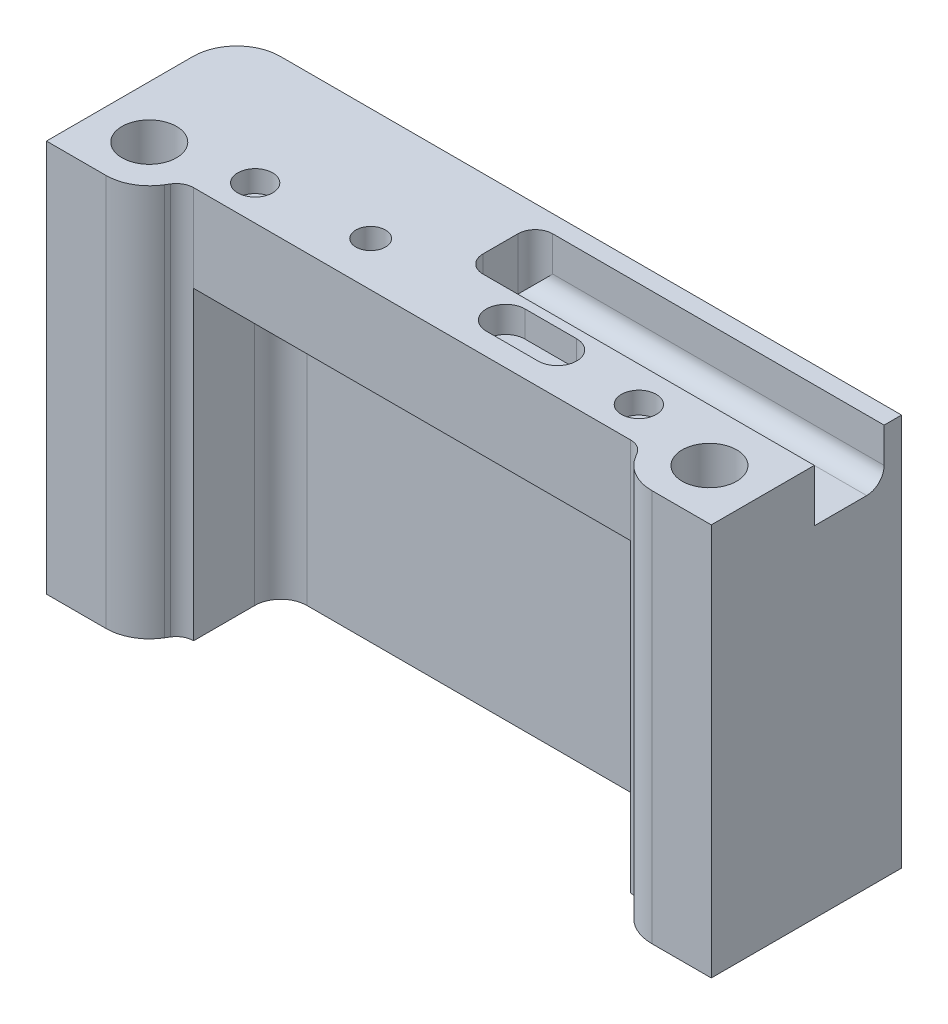
from build123d import *

# Parameters (mm, degrees)
SKETCH1_R                      = 2
SKETCH1_R_2                    = 3.125
SKETCH1_R_3                    = 1.7
BOSS_EXTRUDE1_DEPTH            = 10
FILLET2_R                      = 5
FILLET1_R                      = 2
SKETCH1_4_R                    = 3.125
CUT_EXTRUDE3_DEPTH             = 5.07
SKETCH1_7_R                    = 1.7
CUT_EXTRUDE6_DEPTH             = 10
CUT_EXTRUDE5_DEPTH             = 3
SKETCH1_5_R                    = 2
CUT_EXTRUDE4_DEPTH             = 2.48
SKETCH4_R                      = 1.5
CUT_EXTRUDE7_DEPTH             = 10
SKETCH5_R                      = 2.725
CUT_EXTRUDE8_DEPTH             = 2.8
BOSS_EXTRUDE2_DEPTH            = 10
BOSS_EXTRUDE3_DEPTH            = 35
FILLET13_R                     = 5
SKETCH10_W                     = 8
SKETCH10_H                     = 6
CUT_EXTRUDE12_DEPTH            = 40
FILLET14_R                     = 2
SKETCH27_W                     = 50.098907978
SKETCH27_H                     = 10
CUT_EXTRUDE22_DEPTH            = 35
FILLET17_R                     = 3
CBORE_FOR_M3_SHCS1_D           = 3.4
CBORE_FOR_M3_SHCS1_DEPTH       = 20
CBORE_FOR_M3_SHCS1_CBORE_D     = 6.5
CBORE_FOR_M3_SHCS1_CBORE_DEPTH = 3
CBORE_FOR_M3_SHCS1_TIP         = 1.021463052


with BuildPart() as part:
    # Sketch1 → Boss-Extrude1 (new body)
    with BuildSketch(Plane(origin=(0, 0, 0), x_dir=(1, 0, 0), z_dir=(0, 1, 0))):
        with BuildLine():
            ThreePointArc((-11.409245094, 8.977987014), (-9.849239736, 9.28), (-8.289234378, 8.977987014))
            ThreePointArc((-8.289234378, 8.977987014), (-5.835653376, 8.254222737), (-3.289234378, 8.01))
            Line((-3.289234378, 8.01), (38.12, 8.01))
            Line((38.12, 8.01), (38.12, -3.81))
            Line((38.12, -3.81), (28.478275237, -3.81))
            Line((28.478275237, -3.81), (26.178275237, 0))
            Line((26.178275237, 0), (-26.178275237, 0))
            Line((-26.178275237, 0), (-28.478275237, -3.81))
            Line((-28.478275237, -3.81), (-38.12, -3.81))
            Line((-38.12, -3.81), (-38.12, 8.01))
            Line((-38.12, 8.01), (-16.409245094, 8.01))
            ThreePointArc((-16.409245094, 8.01), (-13.862826096, 8.254222737), (-11.409245094, 8.977987014))
        make_face()
        with Locations((22, 4.005)):
            Circle(SKETCH1_R, mode=Mode.SUBTRACT)
        with Locations((-22, 4.005)):
            Circle(SKETCH1_R, mode=Mode.SUBTRACT)
        with Locations((-32.12, 1.98)):
            Circle(SKETCH1_R_2, mode=Mode.SUBTRACT)
        with Locations((32.12, 1.98)):
            Circle(SKETCH1_R_2, mode=Mode.SUBTRACT)
        with Locations((-9.849239736, 5.1)):
            Circle(SKETCH1_R_3, mode=Mode.SUBTRACT)
        with BuildLine():
            ThreePointArc((11.912105026, 2.53), (14.127105026, 4.745), (11.912105026, 6.96))
            Line((11.912105026, 6.96), (5.992105026, 6.96))
            ThreePointArc((5.992105026, 6.96), (3.777105026, 4.745), (5.992105026, 2.53))
            Line((5.992105026, 2.53), (11.912105026, 2.53))
        make_face(mode=Mode.SUBTRACT)
        with Locations((-22, 4.005)):
            Circle(SKETCH1_R)
        with Locations((-9.849239736, 5.1)):
            Circle(SKETCH1_R_3)
        with Locations((-32.12, 1.98)):
            Circle(SKETCH1_R_2)
        with BuildLine():
            Line((5.992105026, 2.53), (11.912105026, 2.53))
            ThreePointArc((11.912105026, 2.53), (14.127105026, 4.745), (11.912105026, 6.96))
            Line((11.912105026, 6.96), (5.992105026, 6.96))
            ThreePointArc((5.992105026, 6.96), (3.777105026, 4.745), (5.992105026, 2.53))
        make_face()
        with Locations((22, 4.005)):
            Circle(SKETCH1_R)
        with Locations((32.12, 1.98)):
            Circle(SKETCH1_R_2)
    extrude(amount=-BOSS_EXTRUDE1_DEPTH)

    # Fillet2
    fillet2_edges = [part.edges().sort_by_distance(p)[0] for p in [
        (28.478275237, -5, 3.81),
        (-28.478275237, -5, 3.81),
    ]]
    fillet(fillet2_edges, radius=FILLET2_R)

    # Fillet1
    fillet1_edges = [part.edges().sort_by_distance(p)[0] for p in [
        (26.178275237, -5, 0),
        (-26.178275237, -5, 0),
    ]]
    fillet(fillet1_edges, radius=FILLET1_R)

    # Sketch1_4 → Cut-Extrude3 (cut)
    with BuildSketch(Plane(origin=(0, 0, 0), x_dir=(1, 0, 0), z_dir=(0, 1, 0))):
        with Locations(Location((32.12, 1.98, 0), (0, 0, 270))):
            Circle(SKETCH1_4_R)
        with Locations(Location((-32.12, 1.98, 0), (0, 0, 270))):
            Circle(SKETCH1_4_R)
    extrude(amount=-CUT_EXTRUDE3_DEPTH, mode=Mode.SUBTRACT)

    # Sketch1_7 → Cut-Extrude6 (cut)
    with BuildSketch(Plane(origin=(0, 0, 0), x_dir=(1, 0, 0), z_dir=(0, 1, 0))):
        with Locations(Location((-9.849239736, 5.1, 0), (0, 0, 270))):
            Circle(SKETCH1_7_R)
    extrude(amount=-CUT_EXTRUDE6_DEPTH, mode=Mode.SUBTRACT)

    # Sketch1_6 → Cut-Extrude5 (cut)
    with BuildSketch(Plane(origin=(0, 0, 0), x_dir=(1, 0, 0), z_dir=(0, 1, 0))):
        with BuildLine():
            Line((5.992105026, 2.53), (11.912105026, 2.53))
            ThreePointArc((11.912105026, 2.53), (14.127105026, 4.745), (11.912105026, 6.96))
            Line((11.912105026, 6.96), (5.992105026, 6.96))
            ThreePointArc((5.992105026, 6.96), (3.777105026, 4.745), (5.992105026, 2.53))
        make_face()
    extrude(amount=-CUT_EXTRUDE5_DEPTH, mode=Mode.SUBTRACT)

    # Sketch1_5 → Cut-Extrude4 (cut)
    with BuildSketch(Plane(origin=(0, 0, 0), x_dir=(1, 0, 0), z_dir=(0, 1, 0))):
        with Locations(Location((-22, 4.005, 0), (0, 0, 270))):
            Circle(SKETCH1_5_R)
        with Locations(Location((22, 4.005, 0), (0, 0, 270))):
            Circle(SKETCH1_5_R)
    extrude(amount=-CUT_EXTRUDE4_DEPTH, mode=Mode.SUBTRACT)

    # Sketch4 → Cut-Extrude7 (cut)
    with BuildSketch(Plane(origin=(0, 0, 0), x_dir=(1, 0, 0), z_dir=(0, 1, 0))):
        with Locations(Location((-22, 4.005, 0), (0, 0, 270))):
            Circle(SKETCH4_R)
        with Locations(Location((22, 4.005, 0), (0, 0, 270))):
            Circle(SKETCH4_R)
    extrude(amount=-CUT_EXTRUDE7_DEPTH, mode=Mode.SUBTRACT)

    # Sketch5 → Cut-Extrude8 (cut)
    with BuildSketch(Plane.XZ.offset(10)):
        with Locations(Location((22, -4.005, 0), (0, 0, 270))):
            Circle(SKETCH5_R)
        with Locations(Location((-22, -4.005, 0), (0, 0, 90))):
            Circle(SKETCH5_R)
    extrude(amount=-CUT_EXTRUDE8_DEPTH, mode=Mode.SUBTRACT)

    # Sketch6 → Boss-Extrude2 (add)
    with BuildSketch(Plane(origin=(0, 0, 0), x_dir=(1, 0, 0), z_dir=(0, 1, 0))):
        with BuildLine():
            Line((-38.12, 8.01), (-38.12, 18.01))
            Line((-38.12, 18.01), (38.12, 18.01))
            Line((38.12, 18.01), (38.12, 8.01))
            Line((38.12, 8.01), (-3.289234378, 8.01))
            ThreePointArc((-3.289234378, 8.01), (-5.835653376, 8.254222737), (-8.289234378, 8.977987014))
            ThreePointArc((-8.289234378, 8.977987014), (-9.849239736, 9.28), (-11.409245094, 8.977987014))
            ThreePointArc((-11.409245094, 8.977987014), (-13.862826096, 8.254222737), (-16.409245094, 8.01))
            Line((-16.409245094, 8.01), (-38.12, 8.01))
        make_face()
    extrude(amount=-BOSS_EXTRUDE2_DEPTH)

    # Sketch8 → Boss-Extrude3 (add)
    with BuildSketch(Plane.XZ.offset(10)):
        with BuildLine():
            Line((18.950546011, 0), (-18.950546011, 0))
            Line((-18.950546011, 0), (-18.950546011, -4.005))
            ThreePointArc((-18.950546011, -4.005), (-22, -7.054453989), (-25.049453989, -4.005))
            Line((-25.049453989, -4.005), (-25.049453989, 0))
            ThreePointArc((-25.049453989, 0), (-26.032503369, 0.25827272), (-26.761657912, 0.966386084))
            Line((-26.761657912, 0.966386084), (-27.019818549, 1.394034791))
            ThreePointArc((-27.019818549, 1.394034791), (-28.842704905, 3.164318199), (-31.300328355, 3.81))
            Line((-31.300328355, 3.81), (-38.12, 3.81))
            Line((-38.12, 3.81), (-38.12, -18.01))
            Line((-38.12, -18.01), (38.12, -18.01))
            Line((38.12, -18.01), (38.12, 3.81))
            Line((38.12, 3.81), (31.300328355, 3.81))
            ThreePointArc((31.300328355, 3.81), (28.842704905, 3.164318199), (27.019818549, 1.394034791))
            Line((27.019818549, 1.394034791), (26.761657912, 0.966386084))
            ThreePointArc((26.761657912, 0.966386084), (26.032503369, 0.25827272), (25.049453989, 0))
            Line((25.049453989, 0), (25.049453989, -4.005))
            ThreePointArc((25.049453989, -4.005), (22, -7.054453989), (18.950546011, -4.005))
            Line((18.950546011, -4.005), (18.950546011, 0))
        make_face()
    extrude(amount=BOSS_EXTRUDE3_DEPTH)

    # Fillet13
    fillet13_edges = [part.edges().sort_by_distance(p)[0] for p in [
        (-38.12, -22.5, -18.01),
    ]]
    fillet(fillet13_edges, radius=FILLET13_R)

    # Sketch10 → Cut-Extrude12 (cut)
    with BuildSketch(Plane(origin=(38.12, 0, 0), x_dir=(0, 0, -1), z_dir=(1, 0, 0))):
        with Locations((12.01, -3)):
            Rectangle(SKETCH10_W, SKETCH10_H)
    extrude(amount=-CUT_EXTRUDE12_DEPTH, mode=Mode.SUBTRACT)

    # Fillet14
    fillet14_edges = [part.edges().sort_by_distance(p)[0] for p in [
        (-1.88, -3, -16.01),
        (18.12, -6, -16.01),
        (-1.88, -3, -8.01),
    ]]
    fillet(fillet14_edges, radius=FILLET14_R)

    # Sketch27 → Cut-Extrude22 (cut)
    with BuildSketch(Plane.XZ.offset(45)):
        with Locations((0, -5)):
            Rectangle(SKETCH27_W, SKETCH27_H)
    extrude(amount=-CUT_EXTRUDE22_DEPTH, mode=Mode.SUBTRACT)

    # Fillet17
    fillet17_edges = [part.edges().sort_by_distance(p)[0] for p in [
        (-25.049453989, -27.5, -10),
        (25.049453989, -27.5, -10),
    ]]
    fillet(fillet17_edges, radius=FILLET17_R)

    # CBORE for M3 SHCS1
    with Locations(Plane(origin=(0, -53, 22.49), x_dir=(-1, 0, 0), z_dir=(0, -1, 0))):
        with Locations((-5, 36.495), (5, 36.495)):
            CounterBoreHole(CBORE_FOR_M3_SHCS1_D / 2, CBORE_FOR_M3_SHCS1_CBORE_D / 2, CBORE_FOR_M3_SHCS1_CBORE_DEPTH, depth=CBORE_FOR_M3_SHCS1_DEPTH)
            with Locations((0, 0, -(CBORE_FOR_M3_SHCS1_DEPTH + CBORE_FOR_M3_SHCS1_TIP / 2))):  # 118° drill point
                Cone(0, CBORE_FOR_M3_SHCS1_D / 2, CBORE_FOR_M3_SHCS1_TIP, mode=Mode.SUBTRACT)


solid = part.part
